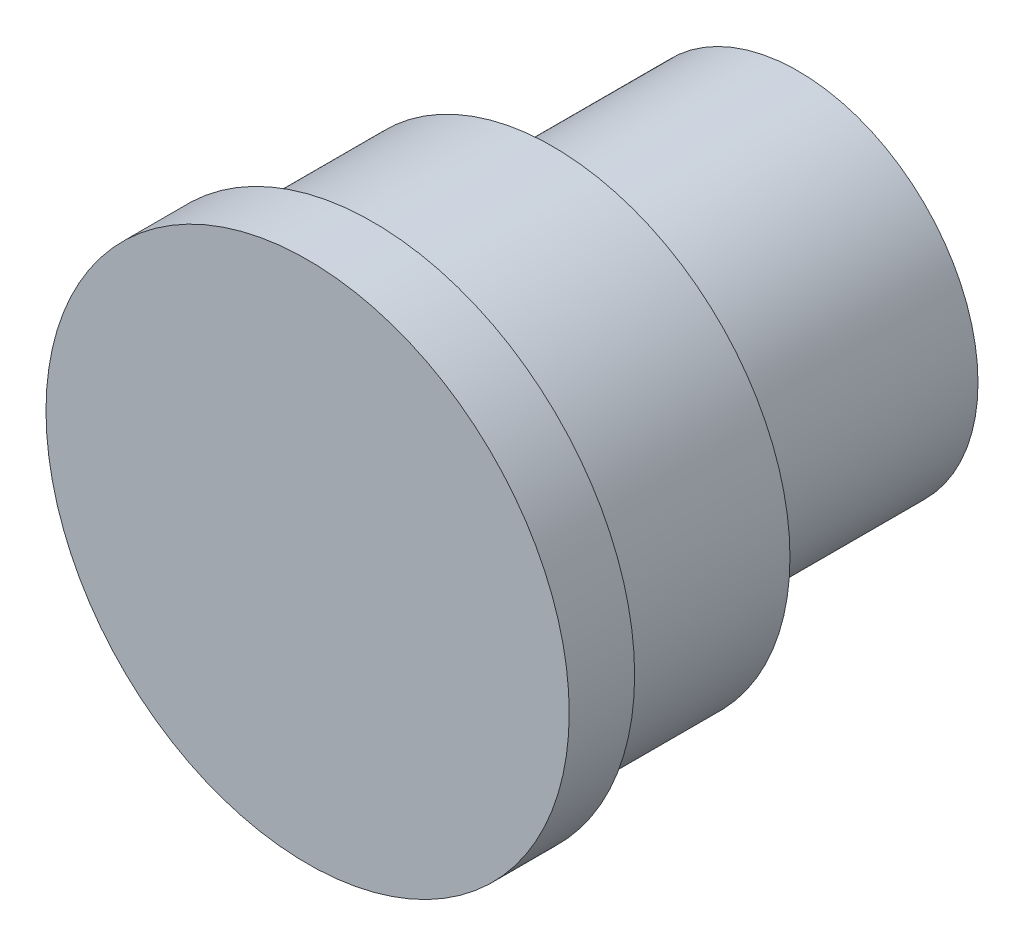
from build123d import *

# Parameters (mm, degrees)
SKETCH_1_R      = 11
EXTRUDE_1_DEPTH = 15
SKETCH_2_R      = 14.5
EXTRUDE_2_DEPTH = 11
SKETCH_3_R      = 16
EXTRUDE_3_DEPTH = 4


with BuildPart() as part:
    # 草图1 → 凸台-拉伸1 (new body)
    with BuildSketch(Plane.XY):
        Circle(SKETCH_1_R)
    extrude(amount=EXTRUDE_1_DEPTH)

    # 草图2 → 凸台-拉伸2 (add)
    with BuildSketch(Plane.XY.offset(15)):
        Circle(SKETCH_2_R)
    extrude(amount=EXTRUDE_2_DEPTH)

    # 草图3 → 凸台-拉伸3 (add)
    with BuildSketch(Plane.XY.offset(26)):
        Circle(SKETCH_3_R)
    extrude(amount=EXTRUDE_3_DEPTH)


solid = part.part
